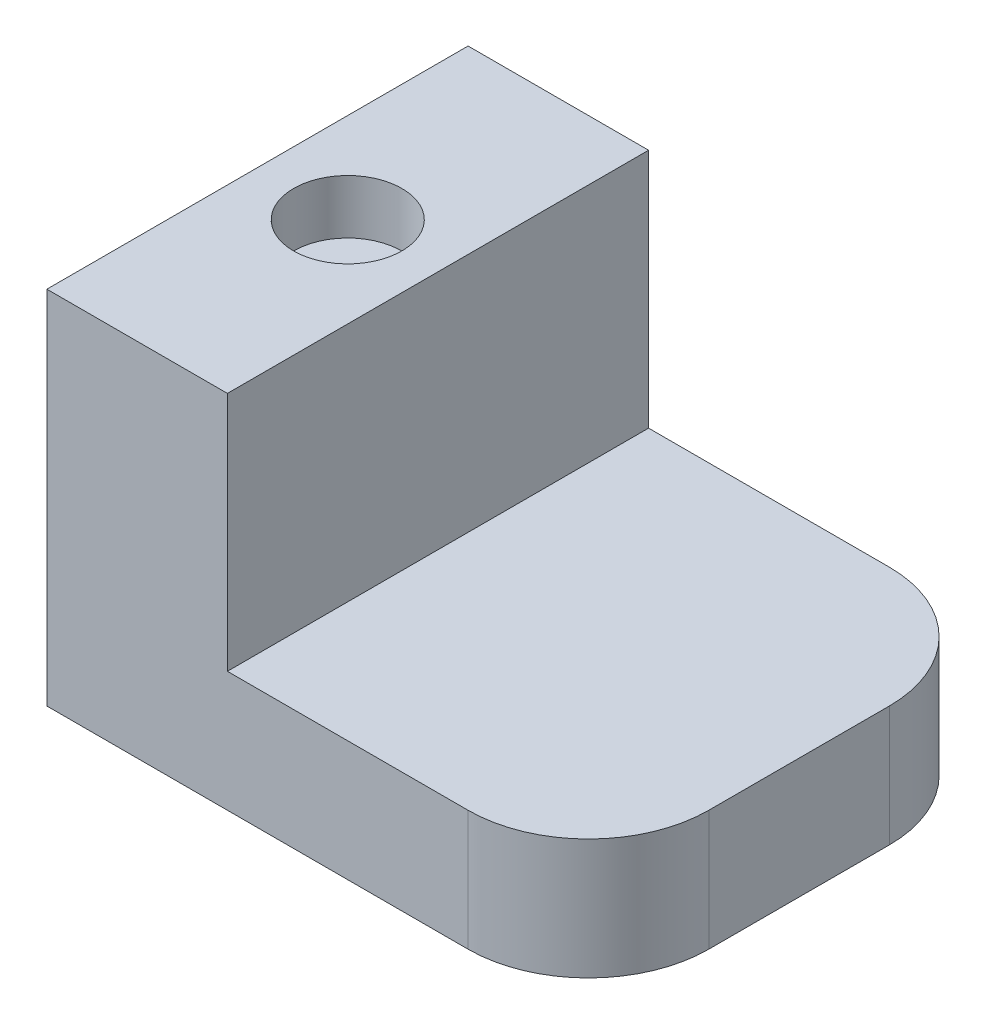
from build123d import *

# Parameters (mm, degrees)
SKETCH_4_W          = 90
SKETCH_4_H          = 60
EXTRUDE_1_DEPTH     = 70
SKETCH_5_W          = 60
SKETCH_5_H          = 40
CUT_EXTRUDE_1_DEPTH = 70
SKETCH_6_R          = 9
CUT_EXTRUDE_2_DEPTH = 9
FILLET_1_R          = 20


with BuildPart() as part:
    # 스케치4 → 보스-돌출1 (new body)
    with BuildSketch(Plane.XY):
        with Locations((45, 30)):
            Rectangle(SKETCH_4_W, SKETCH_4_H)
    extrude(amount=EXTRUDE_1_DEPTH)

    # 스케치5 → 컷-돌출1 (cut)
    with BuildSketch(Plane.XY.offset(70)):
        with Locations((60, 40)):
            Rectangle(SKETCH_5_W, SKETCH_5_H)
    extrude(amount=-CUT_EXTRUDE_1_DEPTH, mode=Mode.SUBTRACT)

    # 스케치6 → 컷-돌출2 (cut)
    with BuildSketch(Plane(origin=(0, 60, 0), x_dir=(1, 0, 0), z_dir=(0, 1, 0))):
        with Locations((15, -35)):
            Circle(SKETCH_6_R)
    extrude(amount=-CUT_EXTRUDE_2_DEPTH, mode=Mode.SUBTRACT)

    # 필렛1
    fillet_1_edges = [part.edges().sort_by_distance(p)[0] for p in [
        (90, 10, 70),
        (90, 10, 0),
    ]]
    fillet(fillet_1_edges, radius=FILLET_1_R)


solid = part.part
